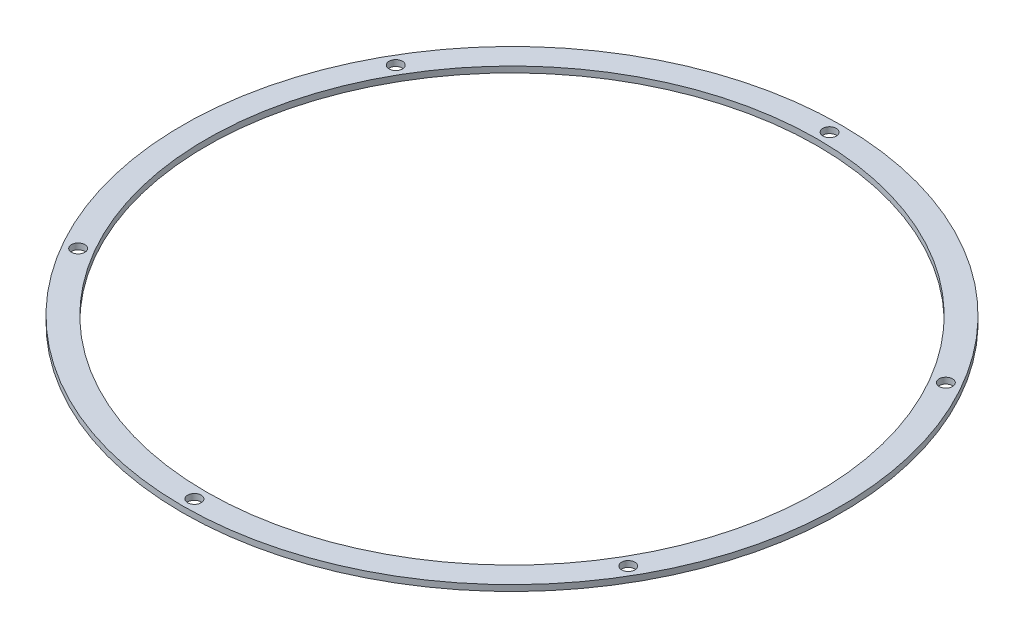
from build123d import *

# Parameters (mm, degrees)
SKETCH1_R           = 174.85
SKETCH1_R_2         = 3.556
SKETCH1_R_3         = 162.15
BOSS_EXTRUDE1_DEPTH = 3.175


with BuildPart() as part:
    # Sketch1 → Boss-Extrude1 (new body)
    with BuildSketch(Plane(origin=(0, 0, 0), x_dir=(1, 0, 0), z_dir=(0, 1, 0))):
        Circle(SKETCH1_R)
        with Locations((0, 168.5)):
            Circle(SKETCH1_R_2, mode=Mode.SUBTRACT)
        with Locations((145.925280538, 84.25)):
            Circle(SKETCH1_R_2, mode=Mode.SUBTRACT)
        with Locations((145.925280538, -84.25)):
            Circle(SKETCH1_R_2, mode=Mode.SUBTRACT)
        with Locations((0, -168.5)):
            Circle(SKETCH1_R_2, mode=Mode.SUBTRACT)
        with Locations((-145.925280538, -84.25)):
            Circle(SKETCH1_R_2, mode=Mode.SUBTRACT)
        with Locations((-145.925280538, 84.25)):
            Circle(SKETCH1_R_2, mode=Mode.SUBTRACT)
        Circle(SKETCH1_R_3, mode=Mode.SUBTRACT)
    extrude(amount=BOSS_EXTRUDE1_DEPTH)


solid = part.part
